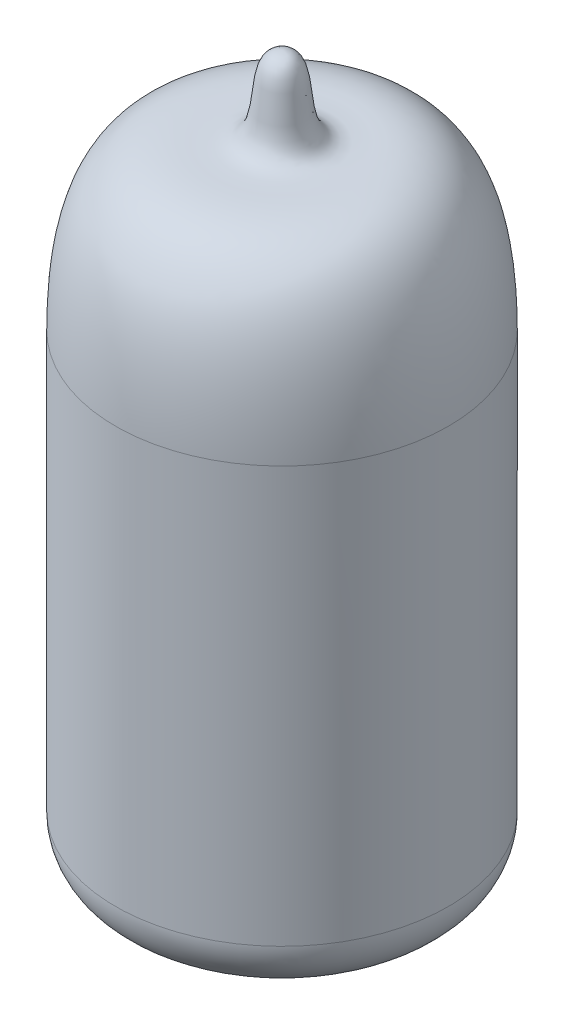
from build123d import *


with BuildPart() as part:
    # Sketch1 → Revolve1 (revolve)
    with BuildSketch(Plane.XY):
        with BuildLine():
            Line((0, 0), (7.5, 0))
            ThreePointArc((7.5, 0), (9.974873734, 1.025126266), (11, 3.5))
            Line((11, 3.5), (11, 31))
            add(Edge.make_bspline(
                [(0, 47), (1.868508868, 47), (0.839979319, 43.098036716), (3.690772078, 40.909332335), (11, 43.731932555), (11, 31)],
                knots=[0, 0, 0, 0, 0.457352926, 0.557352926, 1, 1, 1, 1], degree=3))
            Line((0, 47), (0, 46.7))
            add(Edge.make_bspline(
                [(0, 46.7), (0.089835783, 46.7), (0.286730482, 46.675440139), (0.526826616, 46.561370695), (0.862385089, 46.18251662), (1.044651981, 45.207868135), (1.153282995, 44.076896377), (1.27957898, 43.224881421), (1.526130511, 42.440350235), (2.004678842, 41.769741959), (2.893610253, 41.423589513), (4.086898349, 41.455426541), (5.493916716, 41.46358206), (6.96424187, 41.18629835), (8.123784424, 40.497710935), (8.965606732, 39.51470229), (9.535509298, 38.514305141), (10.020875278, 37.207692702), (10.397250109, 35.559145848), (10.600364695, 33.859238186), (10.685249745, 32.308941091), (10.7, 31.427518579), (10.7, 31)],
                knots=[0, 0, 0, 0, 0.03125, 0.0625, 0.125, 0.25, 0.3125, 0.375, 0.4375, 0.5, 0.5625, 0.625, 0.6875, 0.75, 0.8125, 0.84375, 0.875, 0.90625, 0.9375, 0.96875, 0.984375, 1, 1, 1, 1], degree=3))
            Line((10.7, 31), (10.7, 5.88640066))
            ThreePointArc((10.7, 5.88640066), (9.7627417, 3.62365896), (7.5, 2.68640066))
            Line((7.5, 2.68640066), (0, 2.68640066))
            Line((0, 2.68640066), (0, 0.3))
            Line((0, 0.3), (0, 0))
        make_face()
    revolve(axis=Axis((0, 0, 0), (0, 1, 0)))


solid = part.part
